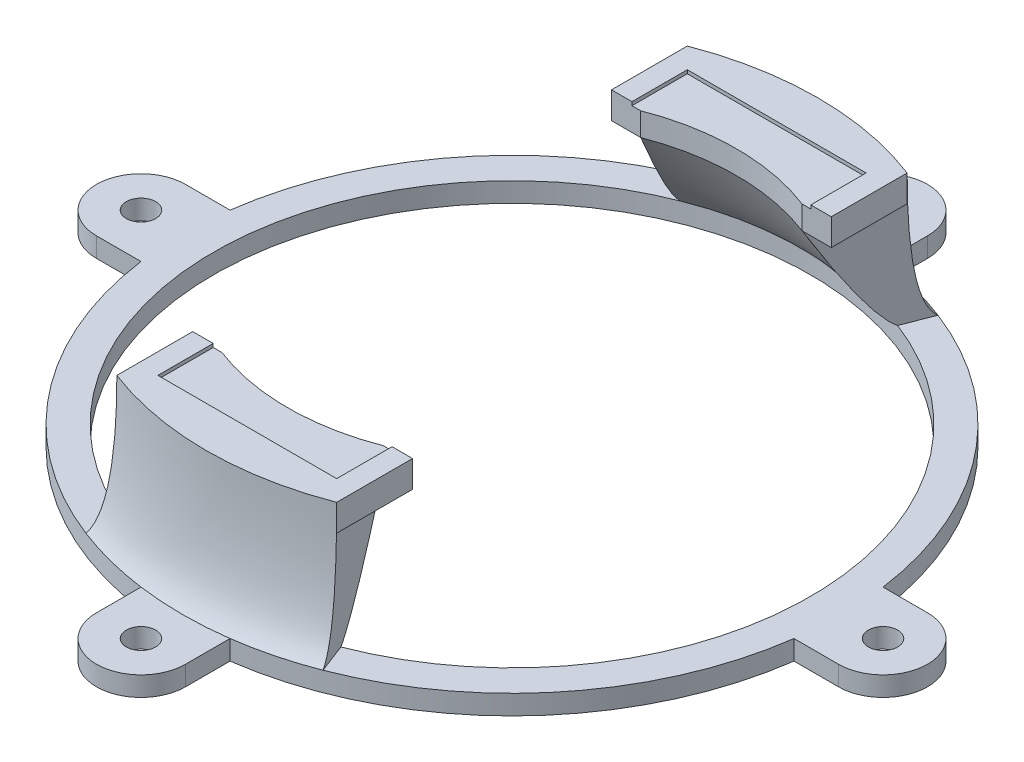
from build123d import *

# Parameters (mm, degrees)
SKETCH1_R           = 2.0955
BOSS_EXTRUDE1_DEPTH = 2.794
SKETCH2_R           = 42.545
CUT_EXTRUDE2_DEPTH  = 3.794
SKETCH4_W           = 31.35
SKETCH4_H           = 81.35
BOSS_EXTRUDE3_DEPTH = 3.81
CIRPATTERN1_COUNT   = 2
SKETCH5_W           = 25.5
SKETCH5_H           = 75.5
CUT_EXTRUDE3_DEPTH  = 0.5
CUT_EXTRUDE5_REACH  = 5.81
SKETCH24_W          = 31.35
SKETCH24_H          = 59.718160102
CUT_EXTRUDE6_START  = -3.31
SKETCH25_R          = 31.999566145
CUT_EXTRUDE6_DEPTH  = 3.31


with BuildPart() as part:
    # Sketch1 → Boss-Extrude1 (new body)
    with BuildSketch(Plane(origin=(0, 0, 0), x_dir=(1, 0, 0), z_dir=(0, 1, 0))):
        with BuildLine():
            Line((46.558969061, 6.35), (52.908969061, 6.35))
            ThreePointArc((52.908969061, 6.35), (59.258969061, 0), (52.908969061, -6.35))
            Line((52.908969061, -6.35), (46.558969061, -6.35))
            ThreePointArc((46.558969061, -6.35), (33.226947648, -33.226947648), (6.35, -46.558969061))
            Line((6.35, -46.558969061), (6.35, -52.908969061))
            ThreePointArc((6.35, -52.908969061), (0, -59.258969061), (-6.35, -52.908969061))
            Line((-6.35, -52.908969061), (-6.35, -46.558969061))
            ThreePointArc((-6.35, -46.558969061), (-33.226947648, -33.226947648), (-46.558969061, -6.35))
            Line((-46.558969061, -6.35), (-52.908969061, -6.35))
            ThreePointArc((-52.908969061, -6.35), (-59.258969061, 0), (-52.908969061, 6.35))
            Line((-52.908969061, 6.35), (-46.558969061, 6.35))
            ThreePointArc((-46.558969061, 6.35), (-33.226947648, 33.226947648), (-6.35, 46.558969061))
            Line((-6.35, 46.558969061), (-6.35, 52.908969061))
            ThreePointArc((-6.35, 52.908969061), (0, 59.258969061), (6.35, 52.908969061))
            Line((6.35, 52.908969061), (6.35, 46.558969061))
            ThreePointArc((6.35, 46.558969061), (33.226947648, 33.226947648), (46.558969061, 6.35))
        make_face()
        with Locations((52.908969061, 0)):
            Circle(SKETCH1_R, mode=Mode.SUBTRACT)
        with Locations((0, -52.908969061)):
            Circle(SKETCH1_R, mode=Mode.SUBTRACT)
        with Locations((-52.908969061, 0)):
            Circle(SKETCH1_R, mode=Mode.SUBTRACT)
        with Locations((0, 52.908969061)):
            Circle(SKETCH1_R, mode=Mode.SUBTRACT)
    extrude(amount=BOSS_EXTRUDE1_DEPTH)

    # Sketch2 → Cut-Extrude2 (cut, through all)
    with BuildSketch(Plane(origin=(0, 2.794, 0), x_dir=(1, 0, 0), z_dir=(0, 1, 0))):
        Circle(SKETCH2_R)
    extrude(amount=-CUT_EXTRUDE2_DEPTH, mode=Mode.SUBTRACT)



with BuildPart() as body_2:
    # Sketch4 → Boss-Extrude3 (new body)
    with BuildSketch(Plane(origin=(0, 21.336, 0), x_dir=(-1, 0, 0), z_dir=(0, -1, 0))):
        Rectangle(SKETCH4_W, SKETCH4_H)
    extrude(amount=BOSS_EXTRUDE3_DEPTH)


with BuildPart() as part_1:
    add(part.part)

    add(body_2.part)  # Sweep2 merges body 2
    # Sweep2: sweep along a path in Sketch22
    with BuildLine(Plane(origin=(0, 2.794, 0), x_dir=(1, 0, 0), z_dir=(0, 1, 0))) as sweep2_path:
        ThreePointArc((15.298922649, 39.699118262), (0, 42.545), (-15.298922649, 39.699118262))
    # Sketch6 → Sweep2 (sweep)
    with BuildSketch(Plane(origin=(0, 0, 0), x_dir=(0.359593904, 0, -0.933108903), z_dir=(0.933108903, 0, 0.359593904))):
        with BuildLine():
            Line((46.99, 2.794), (42.545, 2.794))
            add(Edge.make_bspline(
                [(42.545, 2.794), (38.735, 5.334), (29.845, 21.336)],
                knots=[0, 0, 0, 1, 1, 1], degree=2))
            Line((29.845, 21.336), (43.590839061, 21.336))
            add(Edge.make_bspline(
                [(43.590839061, 21.336), (43.590839061, 5.334), (46.99, 2.794)],
                knots=[0, 0, 0, 1, 1, 1], degree=2))
        make_face()
    sweep2 = sweep(path=sweep2_path.line)

    # CirPattern1: Sweep2 ×2 about axis
    cirpattern1_axis = Axis((0, 0, 0), (0, -1, 0))
    for i in range(1, CIRPATTERN1_COUNT):
        add(sweep2.rotate(cirpattern1_axis, i * 360 / CIRPATTERN1_COUNT))

    # Sketch5 → Cut-Extrude3 (cut)
    with BuildSketch(Plane(origin=(0, 21.336, 0), x_dir=(1, 0, 0), z_dir=(0, 1, 0))):
        Rectangle(SKETCH5_W, SKETCH5_H)
    extrude(amount=-CUT_EXTRUDE3_DEPTH, mode=Mode.SUBTRACT)

    # Sketch24 → Cut-Extrude5 (cut, up to next)
    with BuildSketch(Plane.XZ.offset(-17.526), mode=Mode.PRIVATE) as cut_extrude5_sk1:
        Rectangle(SKETCH24_W, SKETCH24_H)
    cut_extrude5_tool1 = extrude(cut_extrude5_sk1.sketch, amount=-CUT_EXTRUDE5_REACH, mode=Mode.PRIVATE) & part_1.part
    add(cut_extrude5_tool1.solids().sort_by_distance((0, 17.526, 0))[0], mode=Mode.SUBTRACT)

    # Sketch25 → Cut-Extrude6 (cut)
    with BuildSketch(Plane.XZ.offset(-17.526).offset(CUT_EXTRUDE6_START)):
        Circle(SKETCH25_R)
    extrude(amount=CUT_EXTRUDE6_DEPTH, mode=Mode.SUBTRACT)


solid = part_1.part
